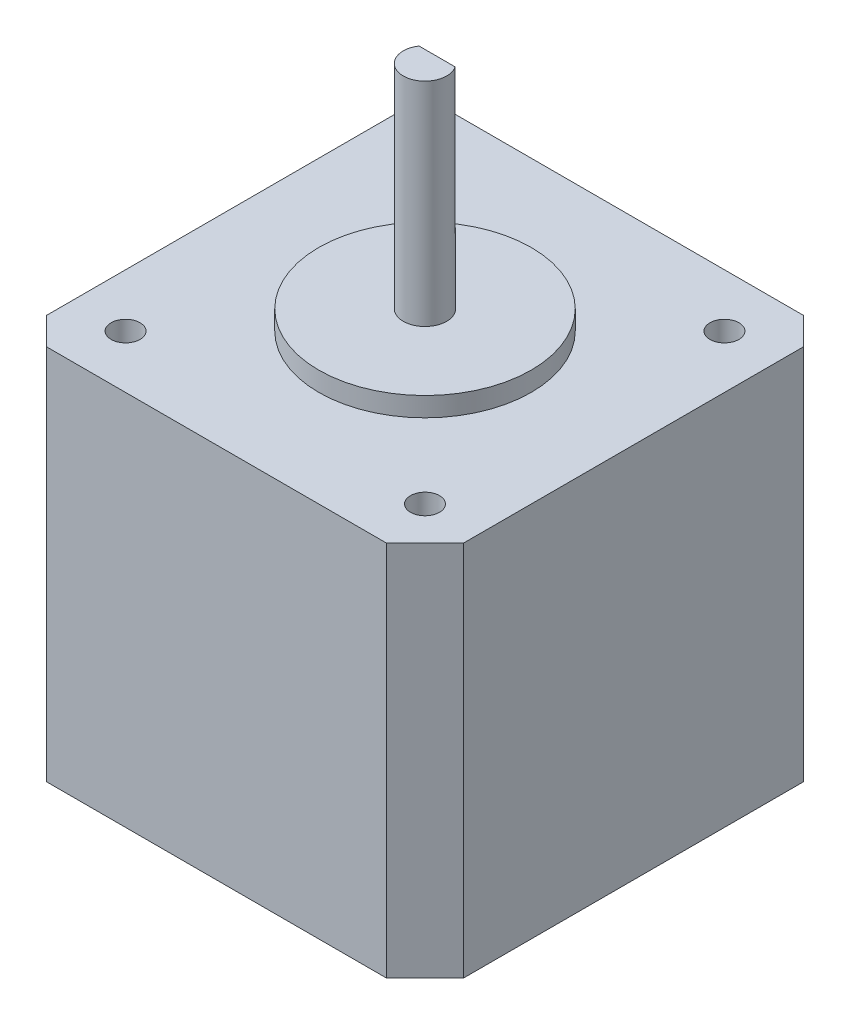
from build123d import *

# Parameters (mm, degrees)
BOSS_EXTRUDE1_DEPTH = 39
SKETCH2_R           = 2.25
BOSS_EXTRUDE2_DEPTH = 24
SKETCH3_R           = 11
BOSS_EXTRUDE3_DEPTH = 2
SKETCH4_R           = 1.5
CUT_EXTRUDE1_DEPTH  = 4.5
CUT_EXTRUDE2_DEPTH  = 15


with BuildPart() as part:
    # Sketch1 → Boss-Extrude1 (new body)
    with BuildSketch(Plane(origin=(0, 0, 0), x_dir=(1, 0, 0), z_dir=(0, 1, 0))):
        Polygon((-21, 18.171572875), (-18.171572875, 21), (18.171572875, 21), (21, 18.171572875), (21, -17), (17, -21), (-18.171572875, -21), (-21, -18.171572875), align=None)
    extrude(amount=BOSS_EXTRUDE1_DEPTH)

    # Sketch2 → Boss-Extrude2 (add)
    with BuildSketch(Plane(origin=(0, 39, 0), x_dir=(1, 0, 0), z_dir=(0, 1, 0))):
        Circle(SKETCH2_R)
    extrude(amount=BOSS_EXTRUDE2_DEPTH)

    # Sketch3 → Boss-Extrude3 (add)
    with BuildSketch(Plane(origin=(0, 39, 0), x_dir=(1, 0, 0), z_dir=(0, 1, 0))):
        Circle(SKETCH3_R)
    extrude(amount=BOSS_EXTRUDE3_DEPTH)

    # Sketch4 → Cut-Extrude1 (cut)
    with BuildSketch(Plane(origin=(0, 39, 0), x_dir=(1, 0, 0), z_dir=(0, 1, 0))):
        with Locations((-15.5, 15.5)):
            Circle(SKETCH4_R)
        with Locations((15.5, 15.5)):
            Circle(SKETCH4_R)
    cut_extrude1 = extrude(amount=-CUT_EXTRUDE1_DEPTH, mode=Mode.SUBTRACT)

    # Mirror1: Cut-Extrude1 across plane
    add(cut_extrude1.mirror(Plane.XY), mode=Mode.SUBTRACT)

    # Sketch5 → Cut-Extrude2 (cut)
    with BuildSketch(Plane(origin=(0, 63, 0), x_dir=(1, 0, 0), z_dir=(0, 1, 0))):
        with BuildLine():
            Line((1.870828693, 1.25), (-1.870828693, 1.25))
            ThreePointArc((-1.870828693, 1.25), (0, 2.25), (1.870828693, 1.25))
        make_face()
    extrude(amount=-CUT_EXTRUDE2_DEPTH, mode=Mode.SUBTRACT)


solid = part.part
